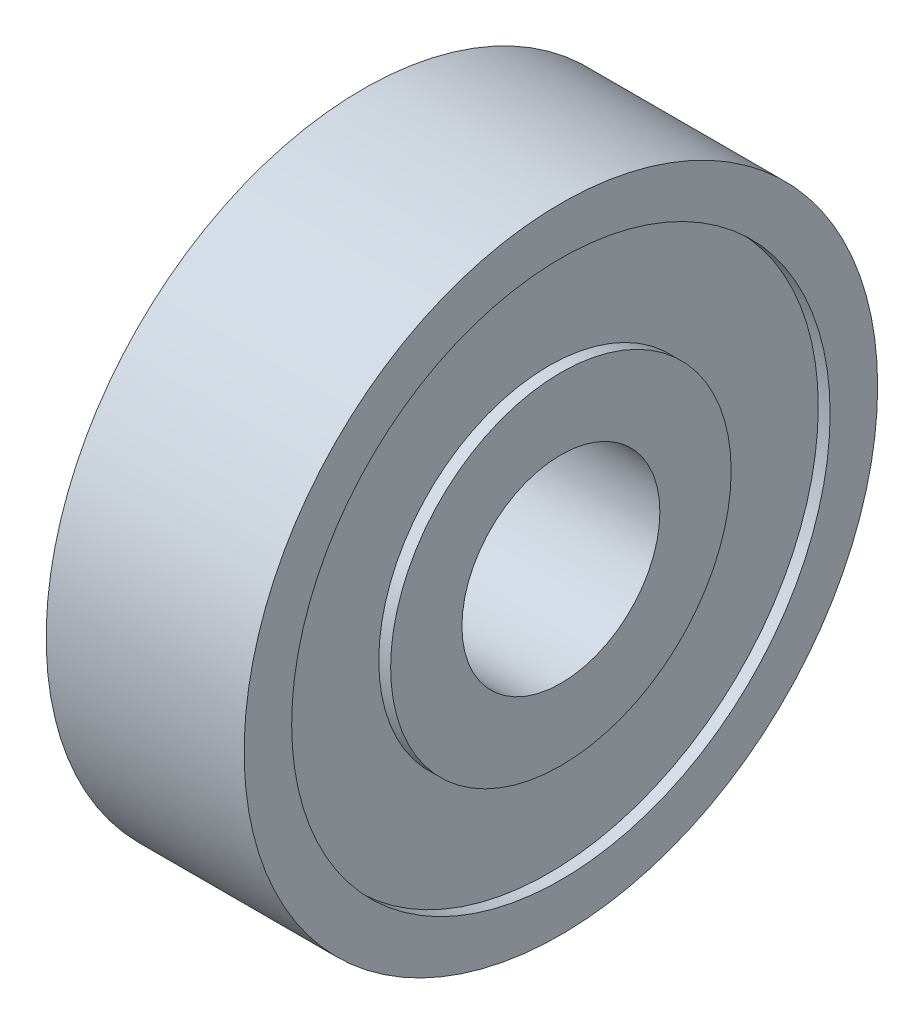
from build123d import *


with BuildPart() as part:
    # Sketch1 → Revolve1 (revolve)
    with BuildSketch(Plane.XY):
        Polygon((2.5, 2.5), (-2.5, 2.5), (-2.5, 4.3), (-2.2, 4.3), (-2.2, 6.8), (-2.5, 6.8), (-2.5, 8), (2.5, 8), (2.5, 6.8), (2.2, 6.8), (2.2, 4.3), (2.5, 4.3), align=None)
    revolve(axis=Axis((0, 0, 0), (-1, 0, 0)))


solid = part.part
